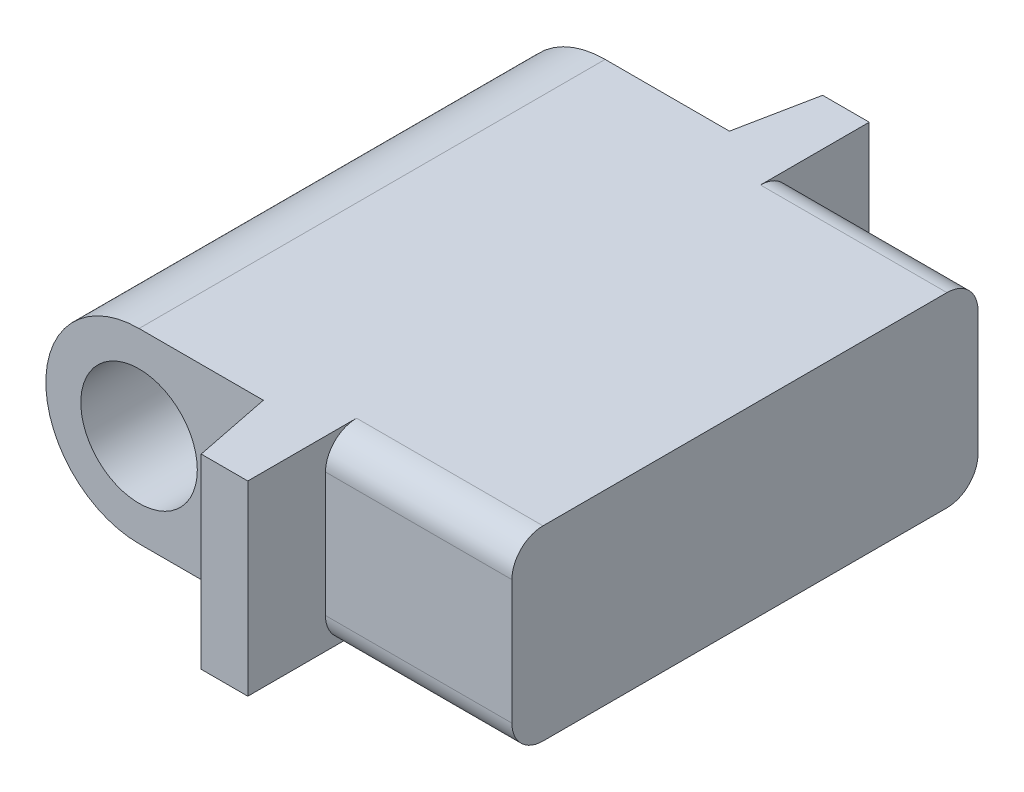
from build123d import *

# Parameters (mm, degrees)
SKETCH1_W           = 38.1
SKETCH1_H           = 50.8
BOSS_EXTRUDE1_DEPTH = 15.24
SKETCH2_W           = 17.78
SKETCH2_H           = 6.35
SKETCH2_W_2         = 15.24
CUT_EXTRUDE1_DEPTH  = 15.24
SKETCH3_R           = 4.7625
CUT_EXTRUDE2_DEPTH  = 45.45
FILLET1_R           = 2.54


with BuildPart() as part:
    # Sketch1 → Boss-Extrude1 (new body)
    with BuildSketch(Plane(origin=(0, 0, 0), x_dir=(1, 0, 0), z_dir=(0, 1, 0))):
        Rectangle(SKETCH1_W, SKETCH1_H)
    extrude(amount=BOSS_EXTRUDE1_DEPTH)

    # Sketch2 → Cut-Extrude1 (cut)
    with BuildSketch(Plane(origin=(0, 15.24, 0), x_dir=(1, 0, 0), z_dir=(0, 1, 0))):
        with Locations((-10.16, 22.225)):
            Rectangle(SKETCH2_W, SKETCH2_H)
        with Locations((11.43, 22.225)):
            Rectangle(SKETCH2_W_2, SKETCH2_H)
        with Locations((-10.16, -22.225)):
            Rectangle(SKETCH2_W, SKETCH2_H)
        with Locations((11.43, -22.225)):
            Rectangle(SKETCH2_W_2, SKETCH2_H)
        Polygon((0, -25.4), (-1.27, -19.05), (-1.27, -25.4), align=None)
        Polygon((0, 25.4), (-1.27, 25.4), (-1.27, 19.05), align=None)
    extrude(amount=-CUT_EXTRUDE1_DEPTH, mode=Mode.SUBTRACT)

    # Sketch3 → Cut-Extrude2 (cut, through all)
    with BuildSketch(Plane.XY.offset(19.05)):
        with BuildLine():
            ThreePointArc((-19.05, 7.62), (-16.818153673, 13.008153673), (-11.43, 15.24))
            Line((-11.43, 15.24), (-19.05, 15.24))
            Line((-19.05, 15.24), (-19.05, 7.62))
        make_face()
        with BuildLine():
            ThreePointArc((-11.43, 0), (-16.818153673, 2.231846327), (-19.05, 7.62))
            Line((-19.05, 7.62), (-19.05, 0))
            Line((-19.05, 0), (-11.43, 0))
        make_face()
        with Locations((-11.43, 7.62)):
            Circle(SKETCH3_R)
    extrude(amount=-CUT_EXTRUDE2_DEPTH, mode=Mode.SUBTRACT)

    # Fillet1
    fillet1_edges = [part.edges().sort_by_distance(p)[0] for p in [
        (11.43, 15.24, 19.05),
        (11.43, 0, 19.05),
        (11.43, 0, -19.05),
        (11.43, 15.24, -19.05),
    ]]
    fillet(fillet1_edges, radius=FILLET1_R)


solid = part.part
